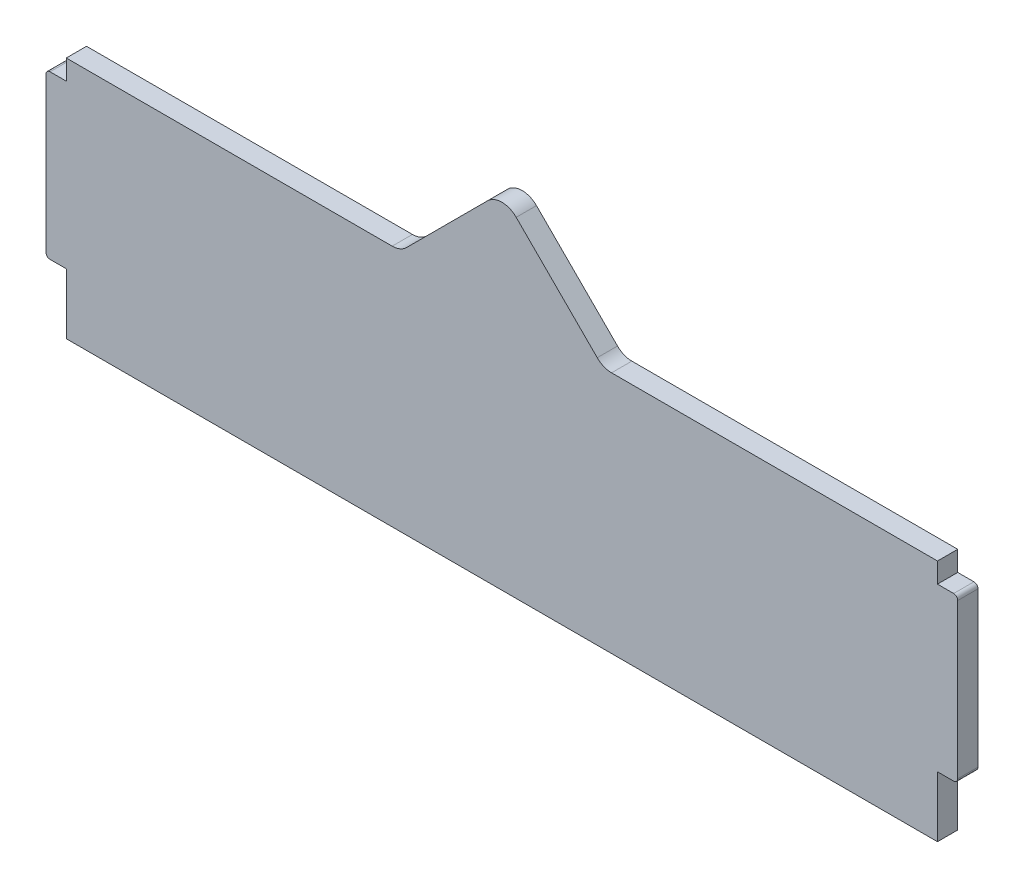
from build123d import *

# Parameters (mm, degrees)
BOSS_EXTRUDE1_DEPTH = 5
FILLET1_R           = 5
FILLET2_R           = 1


with BuildPart() as part:
    # Sketch1 → Boss-Extrude1 (new body)
    with BuildSketch(Plane.XY):
        Polygon((215, 55.05), (215, 60), (132.5, 60), (107.5, 85), (82.5, 60), (0, 60), (0, 55.05), (-5, 55.05), (-5, 14.95), (0, 14.95), (0, 0), (215, 0), (215, 14.95), (220, 14.95), (220, 55.05), align=None)
    extrude(amount=BOSS_EXTRUDE1_DEPTH)

    # Fillet1
    fillet1_edges = [part.edges().sort_by_distance(p)[0] for p in [
        (82.5, 60, 2.5),
        (107.5, 85, 2.5),
        (132.5, 60, 2.5),
    ]]
    fillet(fillet1_edges, radius=FILLET1_R)

    # Fillet2
    fillet2_edges = [part.edges().sort_by_distance(p)[0] for p in [
        (-5, 14.95, 2.5),
        (-5, 55.05, 2.5),
        (220, 55.05, 2.5),
        (220, 14.95, 2.5),
    ]]
    fillet(fillet2_edges, radius=FILLET2_R)


solid = part.part
